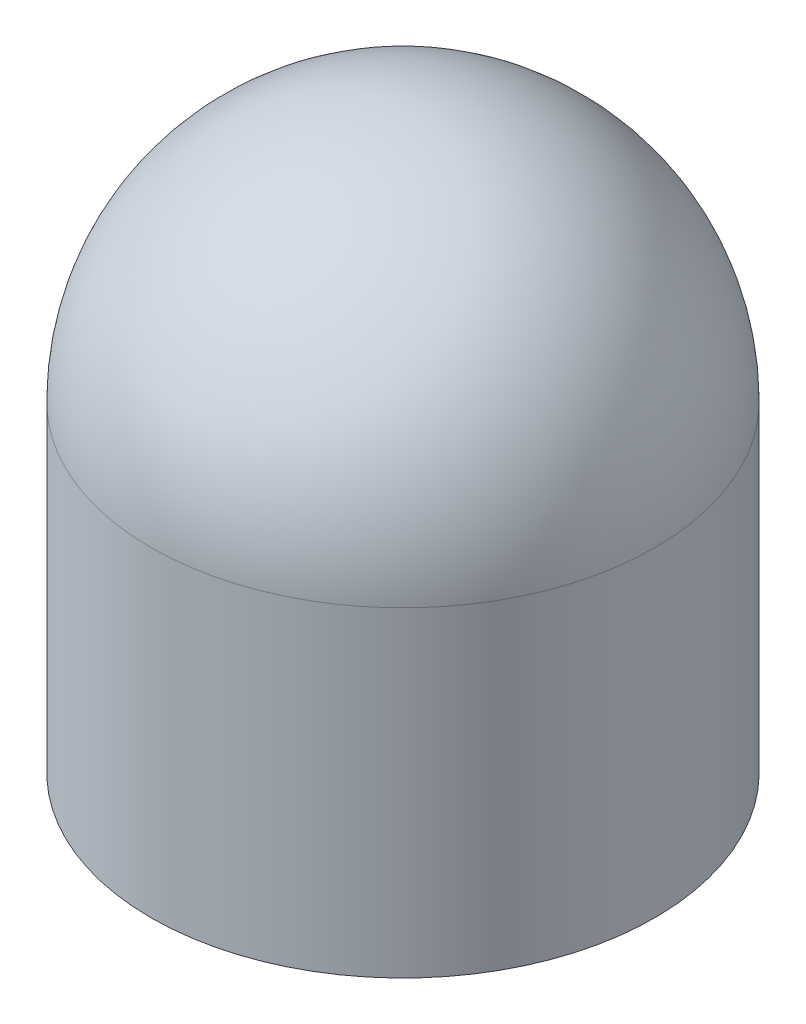
from build123d import *

# Parameters (mm, degrees)
SKETCH1_W           = 3.175
SKETCH1_H           = 12.7
SKETCH2_R           = 66.675
SKETCH2_R_2         = 65.0875
BOSS_EXTRUDE1_DEPTH = 11.1125


with BuildPart() as part:
    # Sketch1 → Revolve3 (revolve)
    with BuildSketch(Plane.XY):
        with BuildLine():
            Line((69.85, 0), (69.85, 76.2))
            ThreePointArc((69.85, 76.2), (49.391408666, 125.591408666), (0, 146.05))
            Line((0, 146.05), (0, 139.7))
            ThreePointArc((0, 139.7), (44.901280605, 121.101280605), (63.5, 76.2))
            Line((63.5, 76.2), (63.5, 0))
            Line((63.5, 0), (69.85, 0))
        make_face()
        with Locations((68.2625, -6.35)):
            Rectangle(SKETCH1_W, SKETCH1_H)
    revolve(axis=Axis((0, 146.05, 0), (0, -1, 0)))

    # Sketch2 → Boss-Extrude1 (add)
    with BuildSketch(Plane(origin=(0, 0, 0), x_dir=(-1, 0, 0), z_dir=(0, -1, 0))):
        Circle(SKETCH2_R)
        Circle(SKETCH2_R_2, mode=Mode.SUBTRACT)
    extrude(amount=BOSS_EXTRUDE1_DEPTH)


solid = part.part
